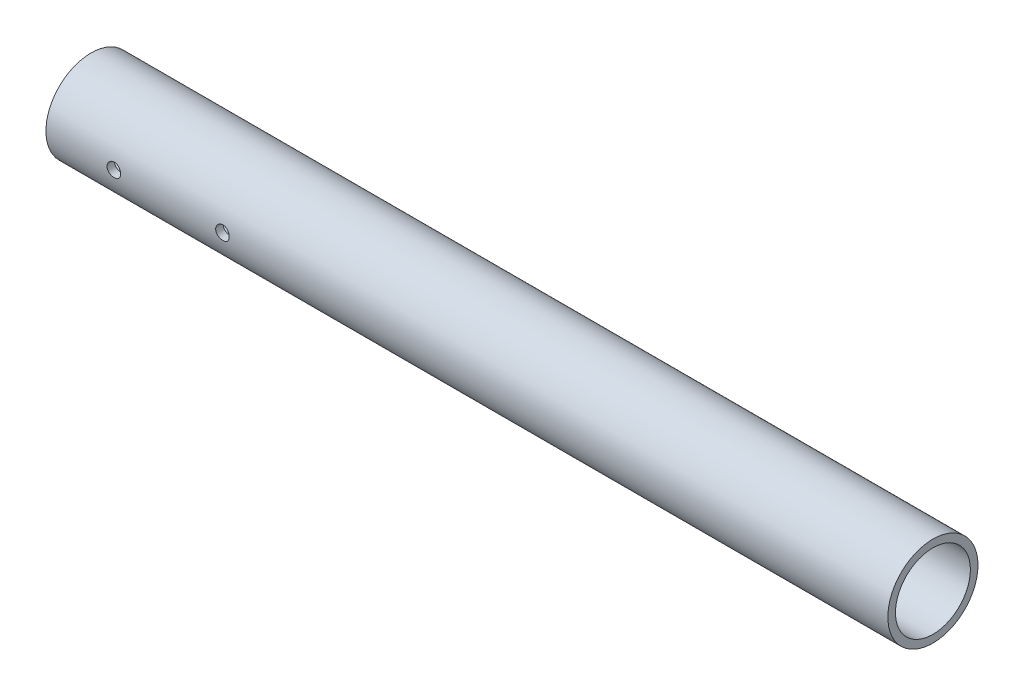
from build123d import *

# Parameters (mm, degrees)
BOSS_EXTRUDE1_DEPTH      = 196.85
BOSS_EXTRUDE1_DEPTH_BACK = 196.85
SKETCH1_R                = 21.082
SKETCH1_R_2              = 17.526
CUT_EXTRUDE1_DEPTH       = 200.095012363
CUT_EXTRUDE1_DEPTH_BACK  = 200.095012363
SKETCH2_R                = 3.175


with BuildPart() as part:
    # Sketch1 → Boss-Extrude1 (new, two sides: drawn at the far end of the back side and taken through both)
    with BuildSketch(Plane(origin=(0, 0, 0), x_dir=(0, 0, -1), z_dir=(1, 0, 0)).offset(-BOSS_EXTRUDE1_DEPTH_BACK)):
        Circle(SKETCH1_R)
        Circle(SKETCH1_R_2, mode=Mode.SUBTRACT)
    extrude(amount=BOSS_EXTRUDE1_DEPTH + BOSS_EXTRUDE1_DEPTH_BACK)

    # Sketch2 → Cut-Extrude1 (cut, two sides: drawn at the far end of the back side and taken through both)
    with BuildSketch(Plane.XY.offset(-CUT_EXTRUDE1_DEPTH_BACK)):
        with Locations((-114.3, 0)):
            Circle(SKETCH2_R)
        with Locations((-165.1, 0)):
            Circle(SKETCH2_R)
    extrude(amount=CUT_EXTRUDE1_DEPTH + CUT_EXTRUDE1_DEPTH_BACK, mode=Mode.SUBTRACT)


solid = part.part
